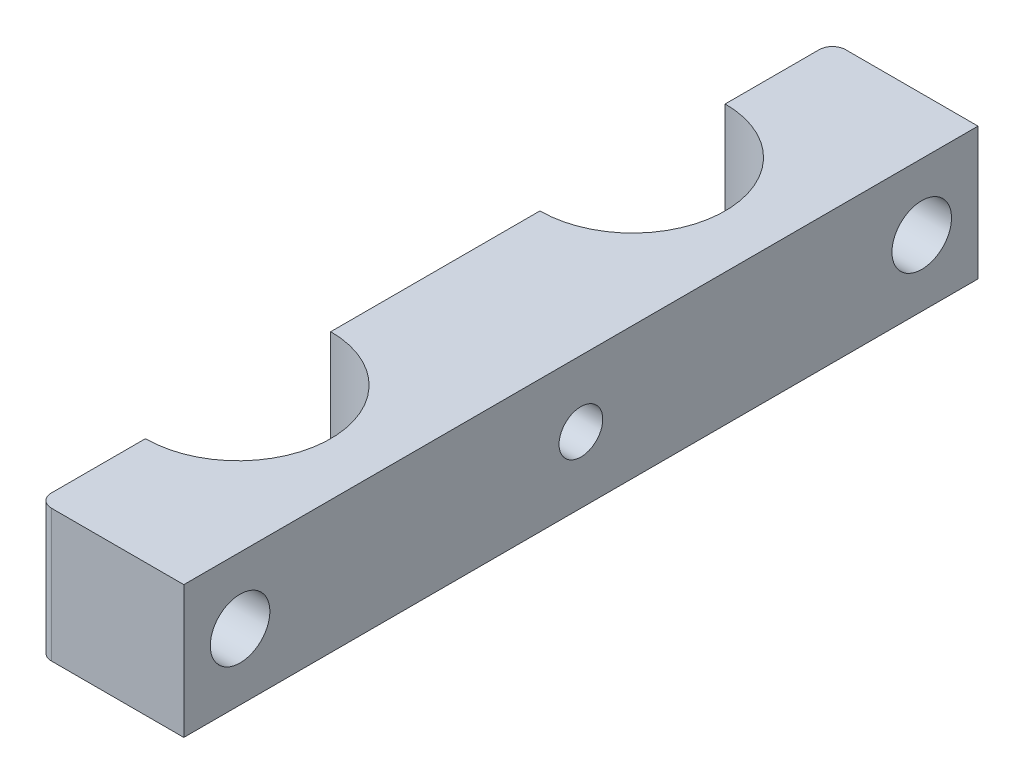
from build123d import *

# Parameters (mm, degrees)
EXTRUDE_1_DEPTH   = 10
FILLET_1_R        = 1
HOLE_WIZARD_M41_D = 4.5
M4X0_71_D         = 3.3


with BuildPart() as part:
    # Эскиз2 → Бобышка-Вытянуть1 (new body)
    with BuildSketch(Plane(origin=(0, 382.645061039, 0), x_dir=(1, 0, 0), z_dir=(0, 1, 0))):
        with BuildLine():
            Line((3.565848943, 102.673881836), (3.565848943, 110.773881836))
            Line((3.565848943, 110.773881836), (14.565848943, 110.773881836))
            Line((14.565848943, 110.773881836), (14.565848943, 50.773881836))
            Line((14.565848943, 50.773881836), (3.565848943, 50.773881836))
            Line((3.565848943, 50.773881836), (3.565848943, 58.873881836))
            ThreePointArc((3.565848943, 58.873881836), (10.565848943, 65.873881836), (3.565848943, 72.873881836))
            Line((3.565848943, 72.873881836), (3.565848943, 88.673881836))
            ThreePointArc((3.565848943, 88.673881836), (10.565848943, 95.673881836), (3.565848943, 102.673881836))
        make_face()
    extrude(amount=-EXTRUDE_1_DEPTH)

    # Скругление1
    fillet_1_edges = [part.edges().sort_by_distance(p)[0] for p in [
        (3.565848943, 377.645061039, -50.773881836),
        (3.565848943, 377.645061039, -110.773881836),
    ]]
    fillet(fillet_1_edges, radius=FILLET_1_R)

    # Отверстие с зазором M41 (through all)
    with Locations(Plane(origin=(3.565848943, 346.946860721, -25.652823237), x_dir=(0, 0, 1), z_dir=(-1, 0, 0))):
        with Locations((-80.8710586, 30.698200318), (-29.3710586, 30.698200318)):
            Hole(HOLE_WIZARD_M41_D / 2)

    # Отверстие обработанное метчиком M4x0.71 (through all)
    with Locations(Plane(origin=(3.565848943, 346.946860721, -25.652823237), x_dir=(0, 0, 1), z_dir=(-1, 0, 0))):
        with Locations((-55.1210586, 30.698200318)):
            Hole(M4X0_71_D / 2)


solid = part.part
